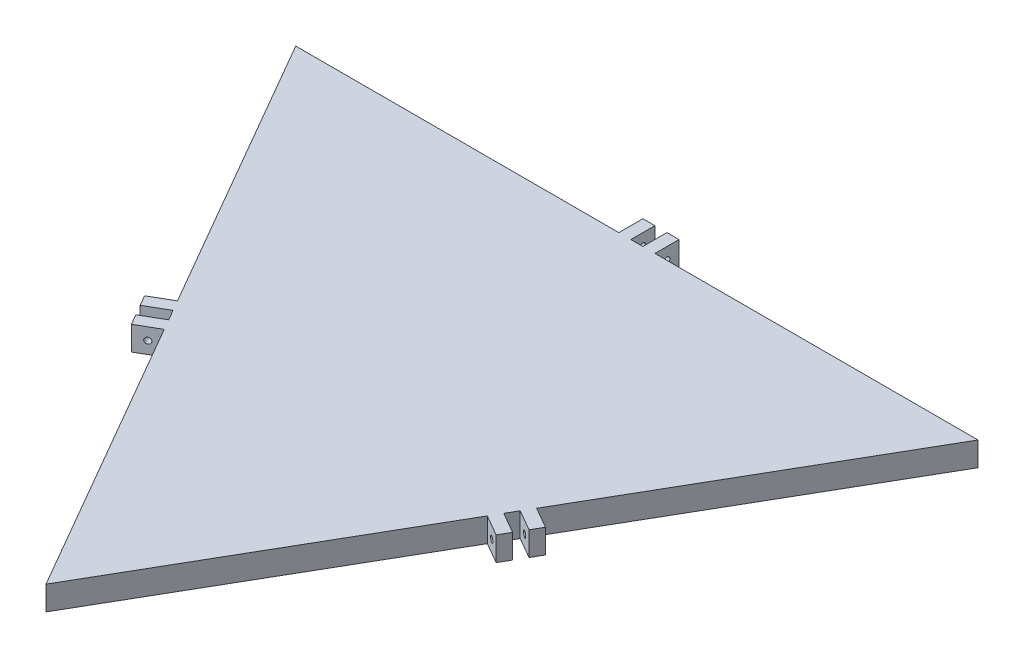
from build123d import *

# Parameters (mm, degrees)
BOSS_EXTRUDE1_DEPTH = 20
SKETCH3_W           = 10
SKETCH3_H           = 20
BOSS_EXTRUDE2_DEPTH = 20
SKETCH4_R           = 2.5
CUT_EXTRUDE1_DEPTH  = 30


with BuildPart() as part:
    # Sketch2 → Boss-Extrude1 (new body)
    with BuildSketch(Plane(origin=(0, 0, 0), x_dir=(1, 0, 0), z_dir=(0, 1, 0))):
        Polygon((-283.5, 163.678801315), (283.5, 163.678801315), (0, -327.357602631), align=None)
    extrude(amount=BOSS_EXTRUDE1_DEPTH)

    # Sketch3 → Boss-Extrude2 (add)
    with BuildSketch(Plane(origin=(141.75, 0, 81.839400658), x_dir=(0.5, 0, -0.866025404), z_dir=(0.866025404, 0, 0.5))):
        with Locations((-10, 10)):
            Rectangle(SKETCH3_W, SKETCH3_H)
        with Locations((10, 10)):
            Rectangle(SKETCH3_W, SKETCH3_H)
    boss_extrude2 = extrude(amount=BOSS_EXTRUDE2_DEPTH)

    # Sketch4 → Cut-Extrude1 (cut)
    with BuildSketch(Plane(origin=(-7.5, 0, 12.990381057), x_dir=(0.866025404, 0, 0.5), z_dir=(-0.5, 0, 0.866025404))):
        with Locations((173.678801315, 10)):
            Circle(SKETCH4_R)
    cut_extrude1 = extrude(amount=-CUT_EXTRUDE1_DEPTH, mode=Mode.SUBTRACT)

    # Mirror1: Boss-Extrude2, Cut-Extrude1 across plane
    add(boss_extrude2.mirror(Plane(origin=(0, 0, 0), x_dir=(-0.866025404, 0, 0.5), z_dir=(0.5, 0, 0.866025404))))
    add(cut_extrude1.mirror(Plane(origin=(0, 0, 0), x_dir=(-0.866025404, 0, 0.5), z_dir=(0.5, 0, 0.866025404))), mode=Mode.SUBTRACT)

    # Mirror1 at the second plane: Boss-Extrude2, Cut-Extrude1 across plane
    add(boss_extrude2.mirror(Plane(origin=(0, 0, 0), x_dir=(0, 0, 1), z_dir=(1, 0, 0))))
    add(cut_extrude1.mirror(Plane(origin=(0, 0, 0), x_dir=(0, 0, 1), z_dir=(1, 0, 0))), mode=Mode.SUBTRACT)


solid = part.part
